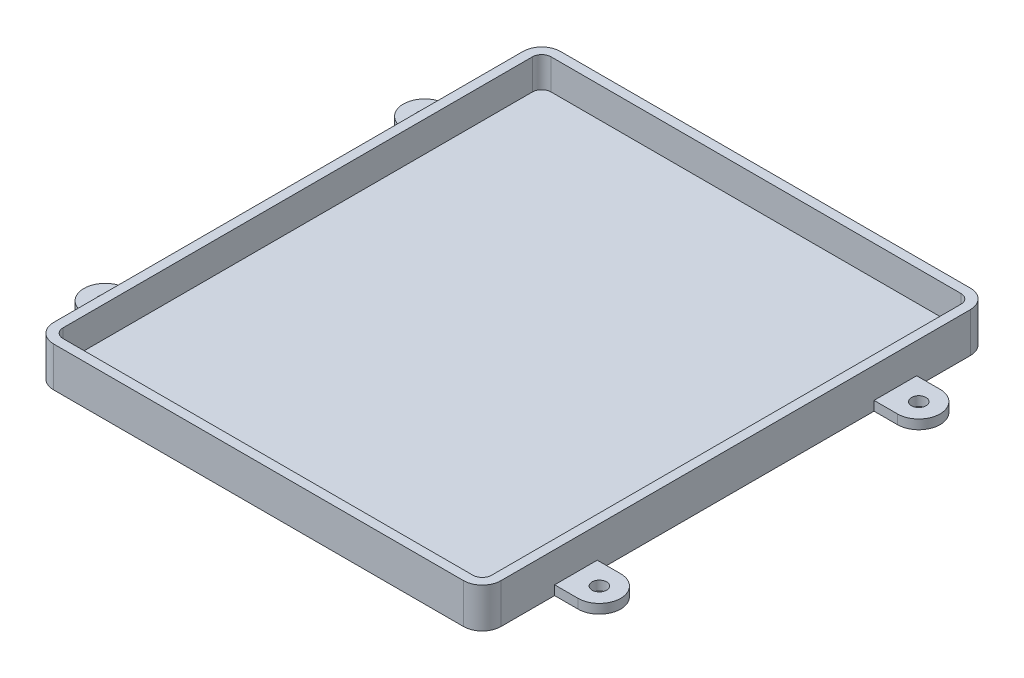
from build123d import *

# Parameters (mm, degrees)
SALIENTE_EXTRUIR1_DEPTH = 8.5
SALIENTE_EXTRUIR2_DEPTH = 2
CROQUIS3_R              = 1.55
SALIENTE_EXTRUIR3_DEPTH = 2


with BuildPart() as part:
    # Croquis1 → Saliente-Extruir1 (new body)
    with BuildSketch(Plane(origin=(0, 0, 0), x_dir=(1, 0, 0), z_dir=(0, 1, 0))):
        with BuildLine():
            Line((-47.75, 50.1), (-47.75, -50.1))
            ThreePointArc((-47.75, -50.1), (-46.578427125, -52.928427125), (-43.75, -54.1))
            Line((-43.75, -54.1), (43.75, -54.1))
            ThreePointArc((43.75, -54.1), (46.578427125, -52.928427125), (47.75, -50.1))
            Line((47.75, -50.1), (47.75, 50.1))
            ThreePointArc((47.75, 50.1), (46.578427125, 52.928427125), (43.75, 54.1))
            Line((43.75, 54.1), (-43.75, 54.1))
            ThreePointArc((-43.75, 54.1), (-46.578427125, 52.928427125), (-47.75, 50.1))
        make_face()
        with BuildLine():
            Line((-43.75, 52.1), (43.75, 52.1))
            ThreePointArc((43.75, 52.1), (45.164213562, 51.514213562), (45.75, 50.1))
            Line((45.75, 50.1), (45.75, -50.1))
            ThreePointArc((45.75, -50.1), (45.164213562, -51.514213562), (43.75, -52.1))
            Line((43.75, -52.1), (-43.75, -52.1))
            ThreePointArc((-43.75, -52.1), (-45.164213562, -51.514213562), (-45.75, -50.1))
            Line((-45.75, -50.1), (-45.75, 50.1))
            ThreePointArc((-45.75, 50.1), (-45.164213562, 51.514213562), (-43.75, 52.1))
        make_face(mode=Mode.SUBTRACT)
    extrude(amount=SALIENTE_EXTRUIR1_DEPTH)

    # Croquis2 → Saliente-Extruir2 (add)
    with BuildSketch(Plane(origin=(0, 0, 0), x_dir=(1, 0, 0), z_dir=(0, 1, 0))):
        with BuildLine():
            Line((43.75, 54.1), (-43.75, 54.1))
            ThreePointArc((-43.75, 54.1), (-46.578427125, 52.928427125), (-47.75, 50.1))
            Line((-47.75, 50.1), (-47.75, -50.1))
            ThreePointArc((-47.75, -50.1), (-46.578427125, -52.928427125), (-43.75, -54.1))
            Line((-43.75, -54.1), (43.75, -54.1))
            ThreePointArc((43.75, -54.1), (46.578427125, -52.928427125), (47.75, -50.1))
            Line((47.75, -50.1), (47.75, 50.1))
            ThreePointArc((47.75, 50.1), (46.578427125, 52.928427125), (43.75, 54.1))
        make_face()
    extrude(amount=SALIENTE_EXTRUIR2_DEPTH)

    # Croquis3 → Saliente-Extruir3 (add)
    with BuildSketch(Plane(origin=(0, 0, 0), x_dir=(1, 0, 0), z_dir=(0, 1, 0))):
        with BuildLine():
            Line((-52.75, 38.65), (-47.75, 38.65))
            Line((-47.75, 38.65), (-47.75, 50.1))
            ThreePointArc((-47.75, 50.1), (-46.578427125, 52.928427125), (-43.75, 54.1))
            Line((-43.75, 54.1), (43.75, 54.1))
            ThreePointArc((43.75, 54.1), (46.578427125, 52.928427125), (47.75, 50.1))
            Line((47.75, 50.1), (47.75, 38.65))
            Line((47.75, 38.65), (52.75, 38.65))
            ThreePointArc((52.75, 38.65), (57.3, 34.1), (52.75, 29.55))
            Line((52.75, 29.55), (47.75, 29.55))
            Line((47.75, 29.55), (47.75, -29.55))
            Line((47.75, -29.55), (52.75, -29.55))
            ThreePointArc((52.75, -29.55), (57.3, -34.1), (52.75, -38.65))
            Line((52.75, -38.65), (47.75, -38.65))
            Line((47.75, -38.65), (47.75, -50.1))
            ThreePointArc((47.75, -50.1), (46.578427125, -52.928427125), (43.75, -54.1))
            Line((43.75, -54.1), (-43.75, -54.1))
            ThreePointArc((-43.75, -54.1), (-46.578427125, -52.928427125), (-47.75, -50.1))
            Line((-47.75, -50.1), (-47.75, -38.65))
            Line((-47.75, -38.65), (-52.75, -38.65))
            ThreePointArc((-52.75, -38.65), (-57.3, -34.1), (-52.75, -29.55))
            Line((-52.75, -29.55), (-47.75, -29.55))
            Line((-47.75, -29.55), (-47.75, 29.55))
            Line((-47.75, 29.55), (-52.75, 29.55))
            ThreePointArc((-52.75, 29.55), (-57.3, 34.1), (-52.75, 38.65))
        make_face()
        with Locations((-52.75, 34.1)):
            Circle(CROQUIS3_R, mode=Mode.SUBTRACT)
        with Locations((52.75, 34.1)):
            Circle(CROQUIS3_R, mode=Mode.SUBTRACT)
        with Locations((52.75, -34.1)):
            Circle(CROQUIS3_R, mode=Mode.SUBTRACT)
        with Locations((-52.75, -34.1)):
            Circle(CROQUIS3_R, mode=Mode.SUBTRACT)
    extrude(amount=SALIENTE_EXTRUIR3_DEPTH)


solid = part.part
